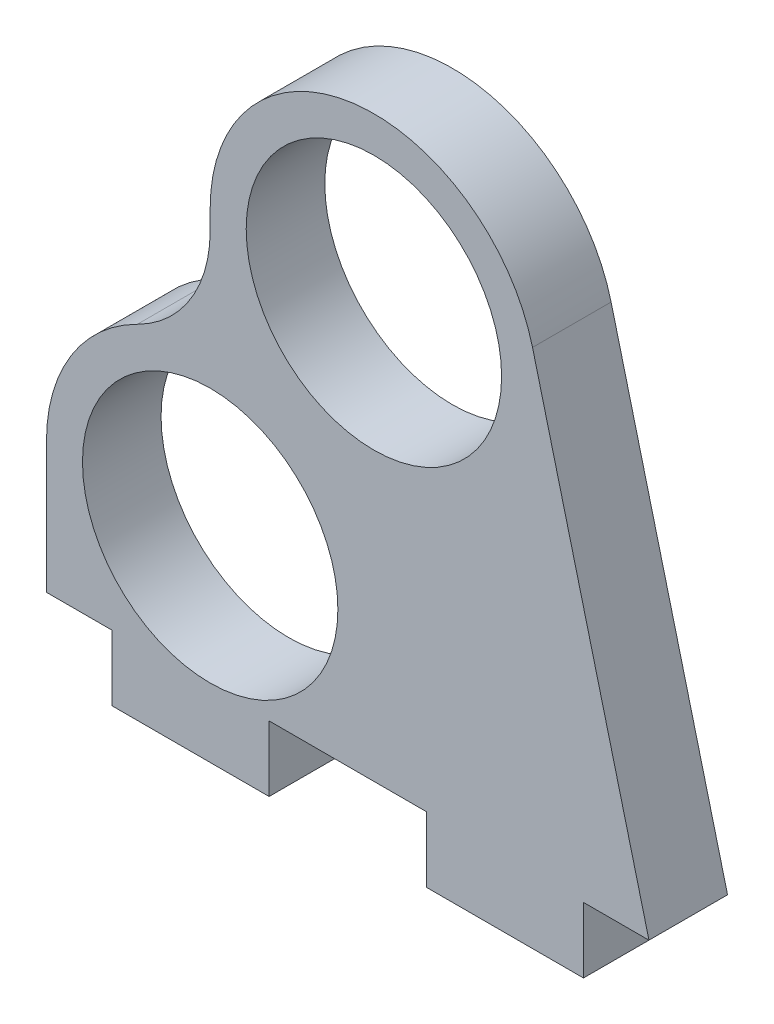
from build123d import *

# Parameters (mm, degrees)
CROQUIS1_R              = 9.75
SALIENTE_EXTRUIR1_DEPTH = 6


with BuildPart() as part:
    # Croquis1 → Saliente-Extruir1 (new body)
    with BuildSketch(Plane.XY):
        with BuildLine():
            Line((-12.5, 0), (-12.5, -10))
            Line((-12.5, -10), (-7.5, -10))
            Line((-7.5, -10), (-7.5, -15))
            Line((-7.5, -15), (4.5, -15))
            Line((4.5, -15), (4.5, -10))
            Line((4.5, -10), (16.5, -10))
            Line((16.5, -10), (16.5, -15))
            Line((16.5, -15), (28.5, -15))
            Line((28.5, -15), (28.5, -10))
            Line((28.5, -10), (33.5, -10))
            Line((33.5, -10), (24.60996669, 24.748813068))
            ThreePointArc((24.60996669, 24.748813068), (10.938683829, 34.052743456), (0, 21.650635095))
            Line((0, 21.650635095), (0, 20.155644371))
            ThreePointArc((0, 20.155644371), (-1.501634144, 14.885181604), (-5.555555556, 11.197580206))
            ThreePointArc((-5.555555556, 11.197580206), (-10.62295732, 6.588078459), (-12.5, 0))
        make_face()
        Circle(CROQUIS1_R, mode=Mode.SUBTRACT)
        with Locations((12.5, 21.650635095)):
            Circle(CROQUIS1_R, mode=Mode.SUBTRACT)
    extrude(amount=SALIENTE_EXTRUIR1_DEPTH)


solid = part.part
